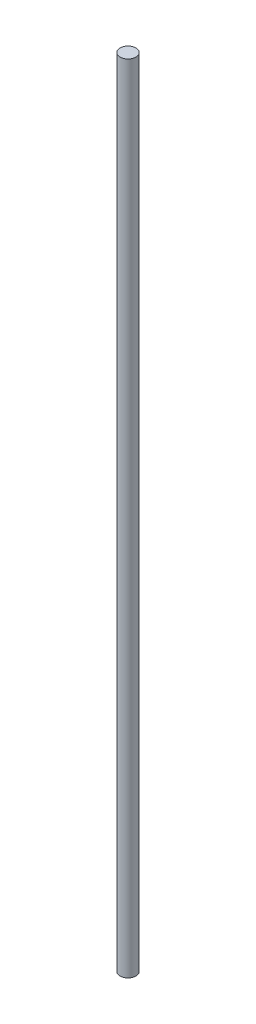
from build123d import *

# Parameters (mm, degrees)
CROQUIS1_R              = 4
SALIENTE_EXTRUIR1_DEPTH = 400


with BuildPart() as part:
    # Croquis1 → Saliente-Extruir1 (new body)
    with BuildSketch(Plane(origin=(0, 0, 0), x_dir=(1, 0, 0), z_dir=(0, 1, 0))):
        Circle(CROQUIS1_R)
    extrude(amount=SALIENTE_EXTRUIR1_DEPTH)


solid = part.part
